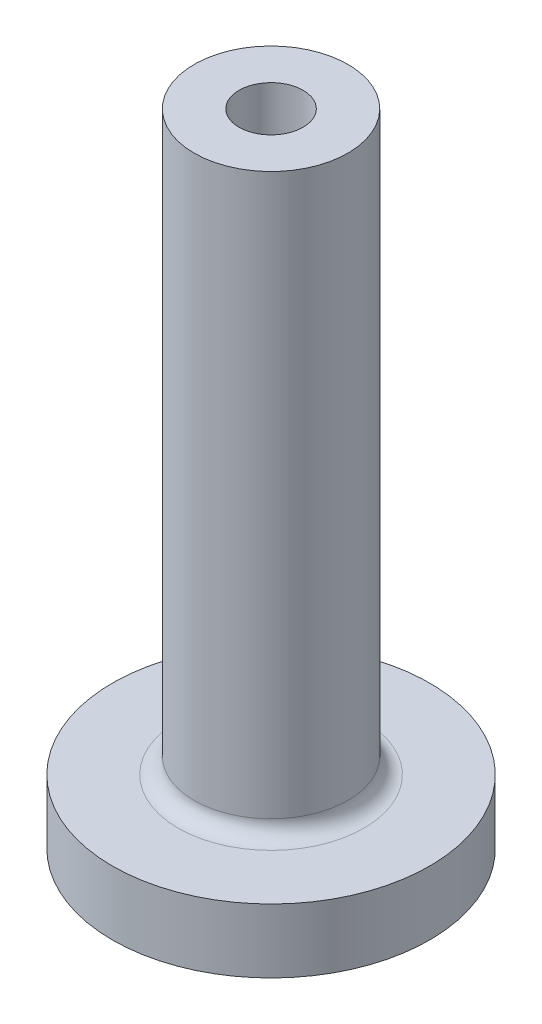
from build123d import *

# Parameters (mm, degrees)
SKETCH1_R           = 9.9
SKETCH1_R_2         = 4.8
SKETCH1_R_3         = 2
BOSS_EXTRUDE1_DEPTH = 4
BOSS_EXTRUDE2_START = 4
SKETCH1_3_R         = 4.8
SKETCH1_3_R_2       = 2
BOSS_EXTRUDE2_DEPTH = 36
CUT_EXTRUDE1_START  = 40
SKETCH1_4_R         = 2
CUT_EXTRUDE1_DEPTH  = 8
FILLET1_R           = 1


with BuildPart() as part:
    # Sketch1 → Boss-Extrude1 (new body)
    with BuildSketch(Plane(origin=(0, 0, 0), x_dir=(1, 0, 0), z_dir=(0, 1, 0))):
        with Locations(Location((0, 0, 0), (0, 0, 270))):
            Circle(SKETCH1_R)
        Circle(SKETCH1_R_2, mode=Mode.SUBTRACT)
        Circle(SKETCH1_R_2)
        Circle(SKETCH1_R_3, mode=Mode.SUBTRACT)
        Circle(SKETCH1_R_3)
    extrude(amount=BOSS_EXTRUDE1_DEPTH)

    # Sketch1_3 → Boss-Extrude2 (add)
    with BuildSketch(Plane(origin=(0, 0, 0), x_dir=(1, 0, 0), z_dir=(0, 1, 0)).offset(BOSS_EXTRUDE2_START)):
        with Locations(Location((0, 0, 0), (0, 0, 270))):
            Circle(SKETCH1_3_R)
        Circle(SKETCH1_3_R_2, mode=Mode.SUBTRACT)
        Circle(SKETCH1_3_R_2)
    extrude(amount=BOSS_EXTRUDE2_DEPTH)

    # Sketch1_4 → Cut-Extrude1 (cut)
    with BuildSketch(Plane(origin=(0, 0, 0), x_dir=(1, 0, 0), z_dir=(0, 1, 0)).offset(CUT_EXTRUDE1_START)):
        with Locations(Location((0, 0, 0), (0, 0, 270))):
            Circle(SKETCH1_4_R)
    extrude(amount=-CUT_EXTRUDE1_DEPTH, mode=Mode.SUBTRACT)

    # Fillet1
    fillet1_edges = [part.edges().sort_by_distance(p)[0] for p in [
        (0, 4, -4.8),
    ]]
    fillet(fillet1_edges, radius=FILLET1_R)


solid = part.part
